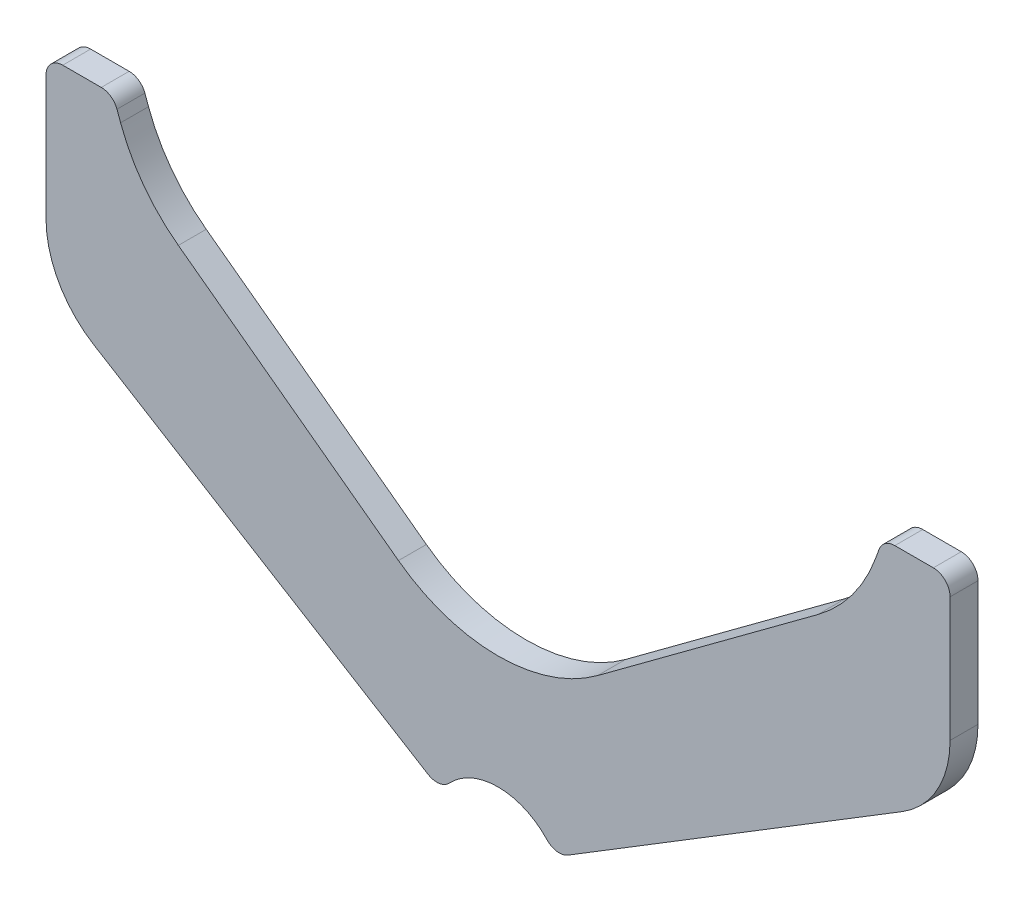
from build123d import *

# Parameters (mm, degrees)
BASE_EXTRUDE_DEPTH = 5


with BuildPart() as part:
    # Sketch1 → Base-Extrude (new body)
    with BuildSketch(Plane.XY):
        with BuildLine():
            Line((-81, 82), (-81, 59.717348192))
            ThreePointArc((-81, 59.717348192), (-78.704928127, 50.922165845), (-72.404974165, 44.369825233))
            Line((-72.404974165, 44.369825233), (-12.531200021, 7.679129249))
            ThreePointArc((-12.531200021, 7.679129249), (-10.560110304, 7.264321725), (-8.770963462, 8.189639794))
            ThreePointArc((-8.770963462, 8.189639794), (0, 12), (8.770963462, 8.189639794))
            ThreePointArc((8.770963462, 8.189639794), (10.560110304, 7.264321725), (12.531200021, 7.679129249))
            Line((12.531200021, 7.679129249), (72.404974165, 44.369825233))
            ThreePointArc((72.404974165, 44.369825233), (78.704928127, 50.922165845), (81, 59.717348192))
            Line((81, 59.717348192), (81, 82))
            ThreePointArc((81, 82), (80.121320344, 84.121320344), (78, 85))
            Line((78, 85), (71.100622615, 85))
            ThreePointArc((71.100622615, 85), (69.379893306, 84.457456133), (68.281544752, 83.02606043))
            Line((68.281544752, 83.02606043), (67.633489632, 81.245543621))
            ThreePointArc((67.633489632, 81.245543621), (63.480325389, 73.556409903), (57.287394611, 67.390442102))
            Line((57.287394611, 67.390442102), (17.844683603, 38.204371262))
            ThreePointArc((17.844683603, 38.204371262), (0, 32.320077081), (-17.844683603, 38.204371262))
            Line((-17.844683603, 38.204371262), (-57.287394611, 67.390442102))
            ThreePointArc((-57.287394611, 67.390442102), (-63.480325389, 73.556409903), (-67.633489632, 81.245543621))
            Line((-67.633489632, 81.245543621), (-68.281544752, 83.02606043))
            ThreePointArc((-68.281544752, 83.02606043), (-69.379893306, 84.457456133), (-71.100622615, 85))
            Line((-71.100622615, 85), (-78, 85))
            ThreePointArc((-78, 85), (-80.121320344, 84.121320344), (-81, 82))
        make_face()
    extrude(amount=BASE_EXTRUDE_DEPTH)


solid = part.part
